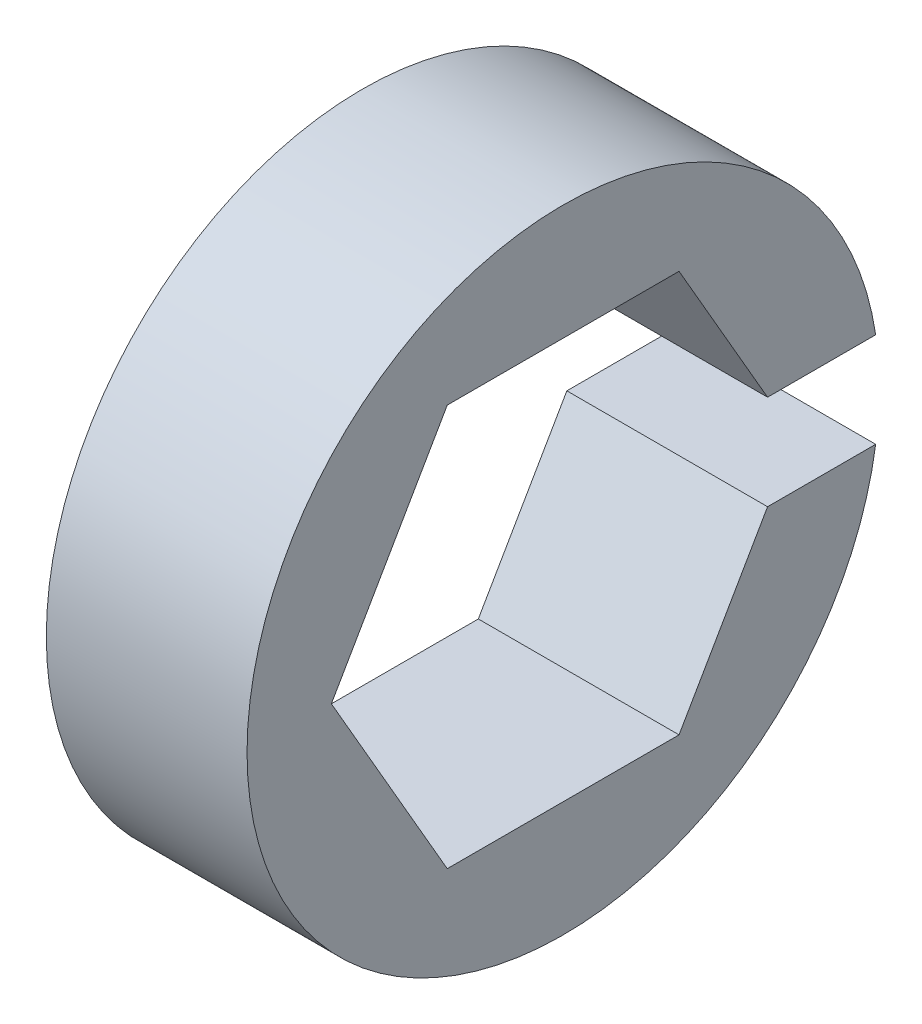
from build123d import *

# Parameters (mm, degrees)
SKETCH1_R           = 10
BOSS_EXTRUDE1_DEPTH = 6.35
SKETCH2_W           = 5.600108675
SKETCH2_H           = 3
CUT_EXTRUDE1_DEPTH  = 7.35


with BuildPart() as part:
    # Sketch1 → Boss-Extrude1 (new body)
    with BuildSketch(Plane(origin=(0, 0, 0), x_dir=(0, 0, -1), z_dir=(1, 0, 0))):
        Circle(SKETCH1_R)
        Polygon((7.332348419, 0), (3.666174209, 6.35), (-3.666174209, 6.35), (-7.332348419, 0), (-3.666174209, -6.35), (3.666174209, -6.35), align=None, mode=Mode.SUBTRACT)
    extrude(amount=BOSS_EXTRUDE1_DEPTH)

    # Sketch2 → Cut-Extrude1 (cut, through all)
    with BuildSketch(Plane(origin=(6.35, 0, 0), x_dir=(0, 0, -1), z_dir=(1, 0, 0))):
        with Locations((8.610205328, 0)):
            Rectangle(SKETCH2_W, SKETCH2_H)
    extrude(amount=-CUT_EXTRUDE1_DEPTH, mode=Mode.SUBTRACT)


solid = part.part
